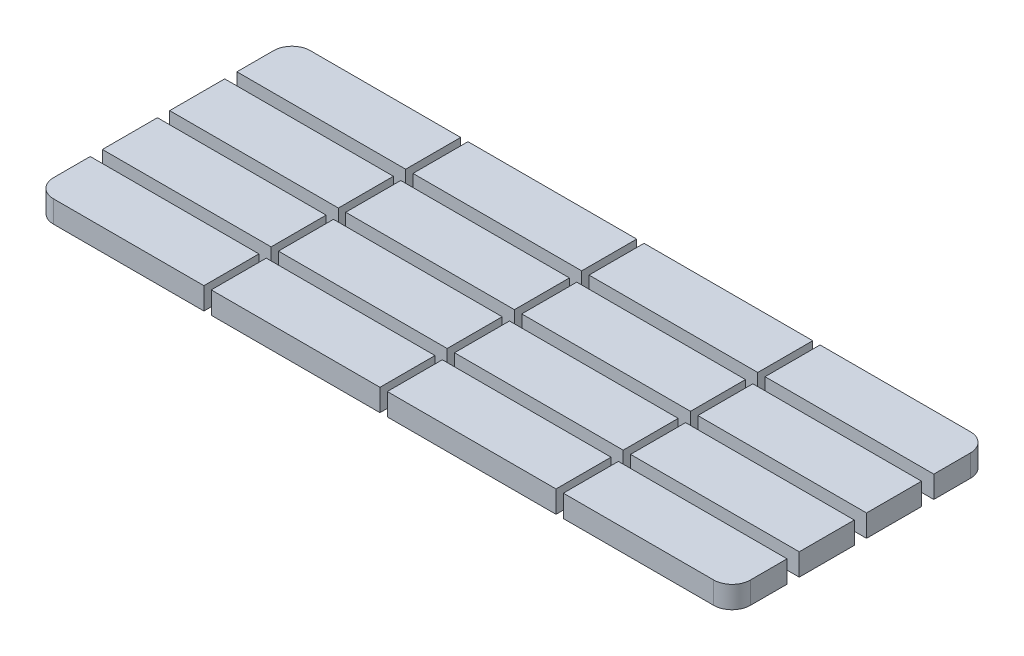
from build123d import *

# Parameters (mm, degrees)
BOSS_EXTRUDE1_DEPTH    = 3
SKETCH1_W              = 23
SKETCH1_H              = 7.5
BOSS_EXTRUDE1_2_DEPTH  = 3
BOSS_EXTRUDE1_3_DEPTH  = 3
BOSS_EXTRUDE1_4_DEPTH  = 3
BOSS_EXTRUDE1_5_DEPTH  = 3
BOSS_EXTRUDE1_6_DEPTH  = 3
BOSS_EXTRUDE1_7_DEPTH  = 3
BOSS_EXTRUDE1_8_DEPTH  = 3
BOSS_EXTRUDE1_9_DEPTH  = 3
BOSS_EXTRUDE1_10_DEPTH = 3
BOSS_EXTRUDE1_11_DEPTH = 3
BOSS_EXTRUDE1_12_DEPTH = 3
BOSS_EXTRUDE1_13_DEPTH = 3
BOSS_EXTRUDE1_14_DEPTH = 3
BOSS_EXTRUDE1_15_DEPTH = 3
BOSS_EXTRUDE1_16_DEPTH = 3


with BuildPart() as part:
    # Sketch1 → Boss-Extrude1 (new body)
    with BuildSketch(Plane(origin=(0, 0, 0), x_dir=(1, 0, 0), z_dir=(0, 1, 0))):
        with BuildLine():
            Line((-54.829059829, 16.67), (-34.329059829, 16.67))
            Line((-34.329059829, 16.67), (-34.329059829, 9.17))
            Line((-34.329059829, 9.17), (-57.329059829, 9.17))
            Line((-57.329059829, 9.17), (-57.329059829, 14.17))
            ThreePointArc((-57.329059829, 14.17), (-56.596826782, 15.937766953), (-54.829059829, 16.67))
        make_face()
    extrude(amount=BOSS_EXTRUDE1_DEPTH)


with BuildPart() as body_2:
    # Sketch1 → Boss-Extrude1 2 (new body)
    with BuildSketch(Plane(origin=(0, 0, 0), x_dir=(1, 0, 0), z_dir=(0, 1, 0))):
        with Locations((-45.829059829, 3.75)):
            Rectangle(SKETCH1_W, SKETCH1_H)
    extrude(amount=BOSS_EXTRUDE1_2_DEPTH)


with BuildPart() as body_3:
    # Sketch1 → Boss-Extrude1 3 (new body)
    with BuildSketch(Plane(origin=(0, 0, 0), x_dir=(1, 0, 0), z_dir=(0, 1, 0))):
        with Locations((-45.829059829, -5.42)):
            Rectangle(SKETCH1_W, SKETCH1_H)
    extrude(amount=BOSS_EXTRUDE1_3_DEPTH)


with BuildPart() as body_4:
    # Sketch1 → Boss-Extrude1 4 (new body)
    with BuildSketch(Plane(origin=(0, 0, 0), x_dir=(1, 0, 0), z_dir=(0, 1, 0))):
        with BuildLine():
            Line((-57.329059829, -10.83), (-57.329059829, -15.83))
            ThreePointArc((-57.329059829, -15.83), (-56.596826782, -17.597766953), (-54.829059829, -18.33))
            Line((-54.829059829, -18.33), (-34.329059829, -18.33))
            Line((-34.329059829, -18.33), (-34.329059829, -10.83))
            Line((-34.329059829, -10.83), (-57.329059829, -10.83))
        make_face()
    extrude(amount=BOSS_EXTRUDE1_4_DEPTH)


with BuildPart() as body_5:
    # Sketch1 → Boss-Extrude1 5 (new body)
    with BuildSketch(Plane(origin=(0, 0, 0), x_dir=(1, 0, 0), z_dir=(0, 1, 0))):
        with Locations((-21.829059829, -14.58)):
            Rectangle(SKETCH1_W, SKETCH1_H)
    extrude(amount=BOSS_EXTRUDE1_5_DEPTH)


with BuildPart() as body_6:
    # Sketch1 → Boss-Extrude1 6 (new body)
    with BuildSketch(Plane(origin=(0, 0, 0), x_dir=(1, 0, 0), z_dir=(0, 1, 0))):
        with Locations((-21.829059829, -5.42)):
            Rectangle(SKETCH1_W, SKETCH1_H)
    extrude(amount=BOSS_EXTRUDE1_6_DEPTH)


with BuildPart() as body_7:
    # Sketch1 → Boss-Extrude1 7 (new body)
    with BuildSketch(Plane(origin=(0, 0, 0), x_dir=(1, 0, 0), z_dir=(0, 1, 0))):
        with Locations((-21.829059829, 3.75)):
            Rectangle(SKETCH1_W, SKETCH1_H)
    extrude(amount=BOSS_EXTRUDE1_7_DEPTH)


with BuildPart() as body_8:
    # Sketch1 → Boss-Extrude1 8 (new body)
    with BuildSketch(Plane(origin=(0, 0, 0), x_dir=(1, 0, 0), z_dir=(0, 1, 0))):
        with Locations((-21.829059829, 12.92)):
            Rectangle(SKETCH1_W, SKETCH1_H)
    extrude(amount=BOSS_EXTRUDE1_8_DEPTH)


with BuildPart() as body_9:
    # Sketch1 → Boss-Extrude1 9 (new body)
    with BuildSketch(Plane(origin=(0, 0, 0), x_dir=(1, 0, 0), z_dir=(0, 1, 0))):
        with Locations((2.170940171, 12.92)):
            Rectangle(SKETCH1_W, SKETCH1_H)
    extrude(amount=BOSS_EXTRUDE1_9_DEPTH)


with BuildPart() as body_10:
    # Sketch1 → Boss-Extrude1 10 (new body)
    with BuildSketch(Plane(origin=(0, 0, 0), x_dir=(1, 0, 0), z_dir=(0, 1, 0))):
        with Locations((2.170940171, 3.75)):
            Rectangle(SKETCH1_W, SKETCH1_H)
    extrude(amount=BOSS_EXTRUDE1_10_DEPTH)


with BuildPart() as body_11:
    # Sketch1 → Boss-Extrude1 11 (new body)
    with BuildSketch(Plane(origin=(0, 0, 0), x_dir=(1, 0, 0), z_dir=(0, 1, 0))):
        with Locations((2.170940171, -14.58)):
            Rectangle(SKETCH1_W, SKETCH1_H)
    extrude(amount=BOSS_EXTRUDE1_11_DEPTH)


with BuildPart() as body_12:
    # Sketch1 → Boss-Extrude1 12 (new body)
    with BuildSketch(Plane(origin=(0, 0, 0), x_dir=(1, 0, 0), z_dir=(0, 1, 0))):
        with BuildLine():
            Line((14.670940171, -18.33), (35.170940171, -18.33))
            ThreePointArc((35.170940171, -18.33), (36.938707124, -17.597766953), (37.670940171, -15.83))
            Line((37.670940171, -15.83), (37.670940171, -10.83))
            Line((37.670940171, -10.83), (14.670940171, -10.83))
            Line((14.670940171, -10.83), (14.670940171, -18.33))
        make_face()
    extrude(amount=BOSS_EXTRUDE1_12_DEPTH)


with BuildPart() as body_13:
    # Sketch1 → Boss-Extrude1 13 (new body)
    with BuildSketch(Plane(origin=(0, 0, 0), x_dir=(1, 0, 0), z_dir=(0, 1, 0))):
        with Locations((26.170940171, -5.42)):
            Rectangle(SKETCH1_W, SKETCH1_H)
    extrude(amount=BOSS_EXTRUDE1_13_DEPTH)


with BuildPart() as body_14:
    # Sketch1 → Boss-Extrude1 14 (new body)
    with BuildSketch(Plane(origin=(0, 0, 0), x_dir=(1, 0, 0), z_dir=(0, 1, 0))):
        with Locations((26.170940171, 3.75)):
            Rectangle(SKETCH1_W, SKETCH1_H)
    extrude(amount=BOSS_EXTRUDE1_14_DEPTH)


with BuildPart() as body_15:
    # Sketch1 → Boss-Extrude1 15 (new body)
    with BuildSketch(Plane(origin=(0, 0, 0), x_dir=(1, 0, 0), z_dir=(0, 1, 0))):
        with Locations((2.170940171, -5.42)):
            Rectangle(SKETCH1_W, SKETCH1_H)
    extrude(amount=BOSS_EXTRUDE1_15_DEPTH)


with BuildPart() as body_16:
    # Sketch1 → Boss-Extrude1 16 (new body)
    with BuildSketch(Plane(origin=(0, 0, 0), x_dir=(1, 0, 0), z_dir=(0, 1, 0))):
        with BuildLine():
            Line((14.670940171, 9.17), (37.670940171, 9.17))
            Line((37.670940171, 9.17), (37.670940171, 14.17))
            ThreePointArc((37.670940171, 14.17), (36.938707124, 15.937766953), (35.170940171, 16.67))
            Line((35.170940171, 16.67), (14.670940171, 16.67))
            Line((14.670940171, 16.67), (14.670940171, 9.17))
        make_face()
    extrude(amount=BOSS_EXTRUDE1_16_DEPTH)


solid = Compound([part.part, body_2.part, body_3.part, body_4.part, body_5.part, body_6.part, body_7.part, body_8.part, body_9.part, body_10.part, body_11.part, body_12.part, body_13.part, body_14.part, body_15.part, body_16.part])
